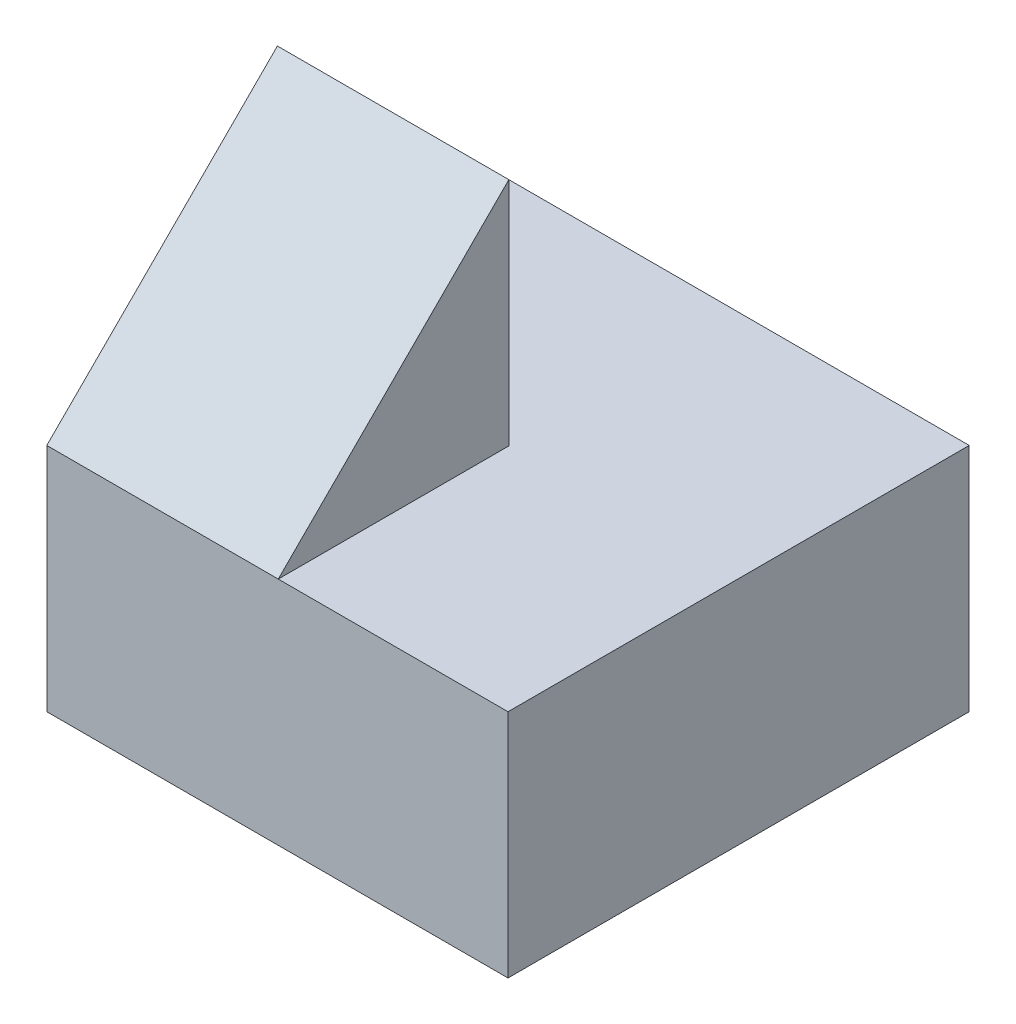
from build123d import *

# Parameters (mm, degrees)
SKETCH1_W           = 4
SKETCH1_H           = 4
BOSS_EXTRUDE1_DEPTH = 4
CUT_EXTRUDE1_DEPTH  = 2
CUT_EXTRUDE2_DEPTH  = 10


with BuildPart() as part:
    # Sketch1 → Boss-Extrude1 (new body)
    with BuildSketch(Plane(origin=(0, 0, 0), x_dir=(1, 0, 0), z_dir=(0, 1, 0))):
        with Locations((2, 2)):
            Rectangle(SKETCH1_W, SKETCH1_H)
    extrude(amount=BOSS_EXTRUDE1_DEPTH)

    # Sketch2 → Cut-Extrude1 (cut)
    with BuildSketch(Plane(origin=(0, 4, 0), x_dir=(1, 0, 0), z_dir=(0, 1, 0))):
        Polygon((0, 4), (0, 2), (2.007512108, 2), (2.007512108, 0), (4, 0), (4, 4), align=None)
    extrude(amount=-CUT_EXTRUDE1_DEPTH, mode=Mode.SUBTRACT)

    # Sketch3 → Cut-Extrude2 (cut)
    with BuildSketch(Plane.ZY):
        Polygon((0, 4), (-2, 4), (0, 2), align=None)
    extrude(amount=-CUT_EXTRUDE2_DEPTH, mode=Mode.SUBTRACT)


solid = part.part
